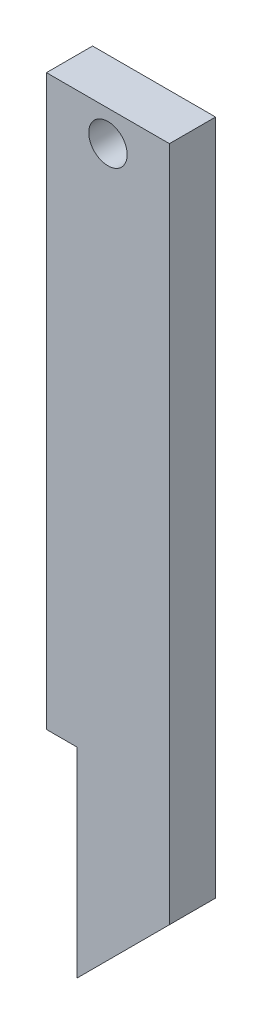
from build123d import *

# Parameters (mm, degrees)
BOSS_EXTRUDE1_DEPTH = 3
SKETCH2_R           = 1.25
CUT_EXTRUDE1_DEPTH  = 3


with BuildPart() as part:
    # Sketch1 → Boss-Extrude1 (new body)
    with BuildSketch(Plane.XY):
        Polygon((-9.553498798, 42.962261971), (-9.553498798, -1.037738029), (-17.553498798, -9.037738029), (-17.553498798, 42.962261971), align=None)
    extrude(amount=BOSS_EXTRUDE1_DEPTH)

    # Sketch2 → Cut-Extrude1 (cut)
    with BuildSketch(Plane.XY.offset(3)):
        with Locations((-13.553498798, 40.962261971)):
            Circle(SKETCH2_R)
        Polygon((-17.553498798, -9.037738029), (-17.553498798, 5.962261971), (-15.553498798, 5.962261971), (-15.553498798, -7.037738029), align=None)
    extrude(amount=-CUT_EXTRUDE1_DEPTH, mode=Mode.SUBTRACT)


solid = part.part
